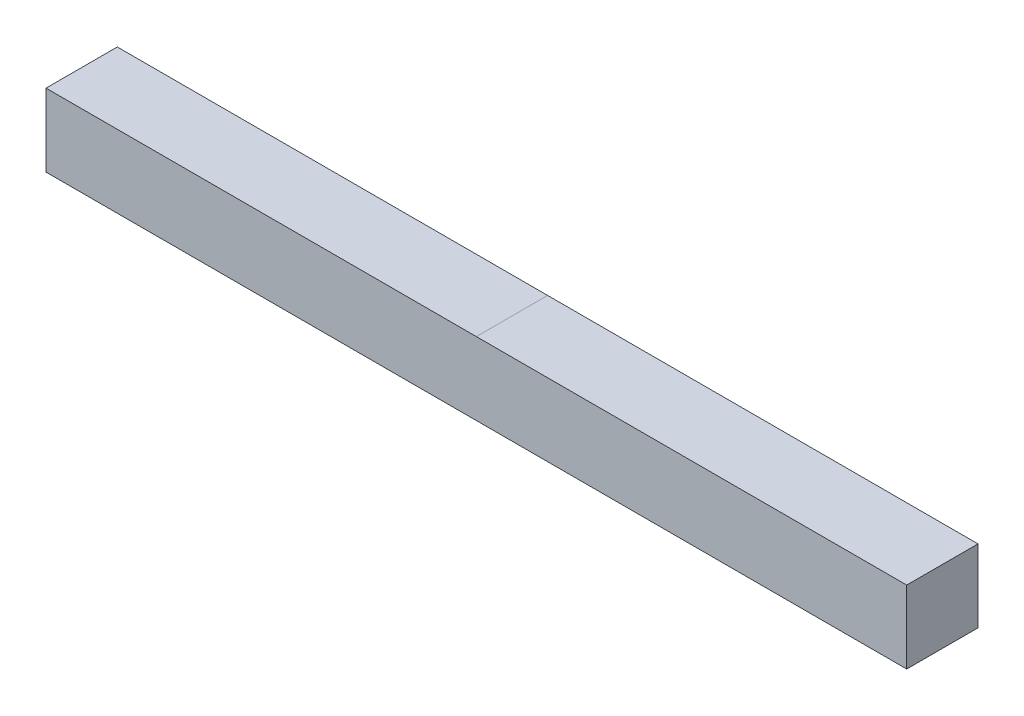
from build123d import *

# Parameters (mm, degrees)
SKETCH1_W           = 12.6238
SKETCH1_H           = 12.8778
BOSS_EXTRUDE1_DEPTH = 76.2


with BuildPart() as part:
    # Sketch1 → Boss-Extrude1 (new body, symmetric)
    with BuildSketch(Plane(origin=(0, 0, 0), x_dir=(0, 0, -1), z_dir=(1, 0, 0))):
        Rectangle(SKETCH1_W, SKETCH1_H)
    extrude(amount=BOSS_EXTRUDE1_DEPTH, both=True)


solid = part.part
